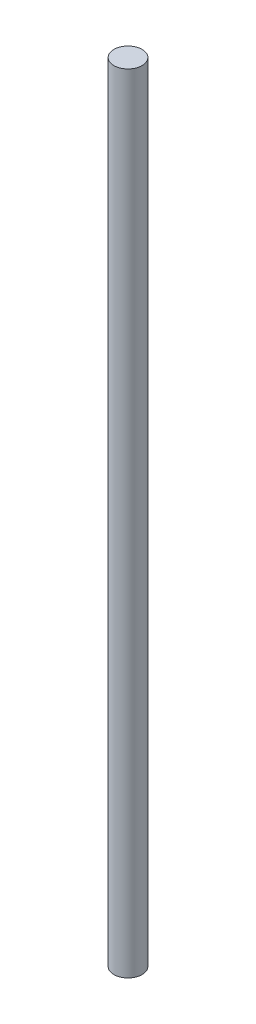
from build123d import *

# Parameters (mm, degrees)
SKETCH1_R           = 3.175
BOSS_EXTRUDE1_DEPTH = 88.9


with BuildPart() as part:
    # Sketch1 → Boss-Extrude1 (new body, symmetric)
    with BuildSketch(Plane(origin=(0, 0, 0), x_dir=(1, 0, 0), z_dir=(0, 1, 0))):
        Circle(SKETCH1_R)
    extrude(amount=BOSS_EXTRUDE1_DEPTH, both=True)


solid = part.part
